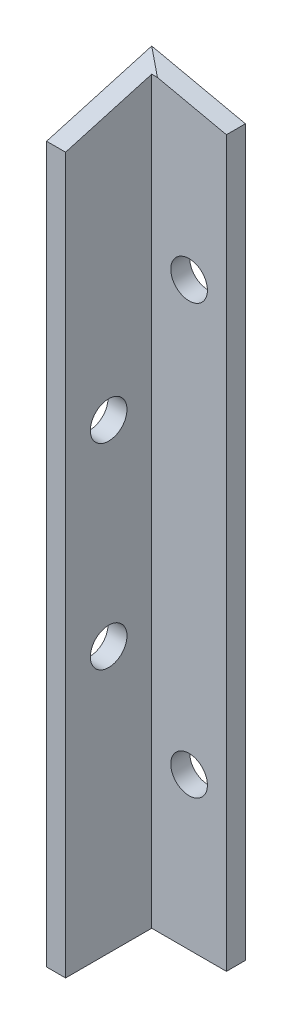
from build123d import *

# Parameters (mm, degrees)
BOSS_EXTRUDE1_DEPTH = 100
CUT_EXTRUDE5_DEPTH  = 16
CUT_EXTRUDE6_DEPTH  = 16
SKETCH8_R           = 2.415
CUT_EXTRUDE7_DEPTH  = 16
SKETCH6_R           = 2.415
CUT_EXTRUDE8_DEPTH  = 16


with BuildPart() as part:
    # Sketch1 → Boss-Extrude1 (new body)
    with BuildSketch(Plane(origin=(0, 0, 0), x_dir=(1, 0, 0), z_dir=(0, 1, 0))):
        Polygon((0, 0), (0, 13.85), (12.34, 13.85), (12.34, 11.35), (2.5, 11.35), (2.5, 0), align=None)
    extrude(amount=BOSS_EXTRUDE1_DEPTH)

    # Sketch5 → Cut-Extrude5 (cut)
    with BuildSketch(Plane(origin=(0, 0, -13.85), x_dir=(-1, 0, 0), z_dir=(0, 0, -1))):
        Polygon((0, 98.157512876), (-15.02502343, 99.39968578), (-15.02502343, 94.867790228), align=None)
    extrude(amount=-CUT_EXTRUDE5_DEPTH, mode=Mode.SUBTRACT)


with BuildPart() as body_2:
    # of the pieces the cut leaves, the one that is kept (cut_extrude5_keep)
    add(part.part.solids().sort_by_distance((0, 0, 0))[0])

    # Sketch4 → Cut-Extrude6 (cut)
    with BuildSketch(Plane.ZY):
        Polygon((-13.849977668, 98.157512876), (8.264271821, 91.866448074), (8.264271821, 98.157512876), align=None)
    extrude(amount=-CUT_EXTRUDE6_DEPTH, mode=Mode.SUBTRACT)

    # Sketch8 → Cut-Extrude7 (cut)
    with BuildSketch(Plane(origin=(2.5, 0, 0), x_dir=(0, 0, -1), z_dir=(1, 0, 0))):
        with Locations((5.675, 35)):
            Circle(SKETCH8_R)
        with Locations((5.675, 60.83189408)):
            Circle(SKETCH8_R)
    extrude(amount=-CUT_EXTRUDE7_DEPTH, mode=Mode.SUBTRACT)

    # Sketch6 → Cut-Extrude8 (cut)
    with BuildSketch(Plane.XY.offset(-11.35)):
        with Locations((7.42, 20)):
            Circle(SKETCH6_R)
        with Locations((7.42, 76.450996936)):
            Circle(SKETCH6_R)
    extrude(amount=-CUT_EXTRUDE8_DEPTH, mode=Mode.SUBTRACT)


solid = body_2.part
